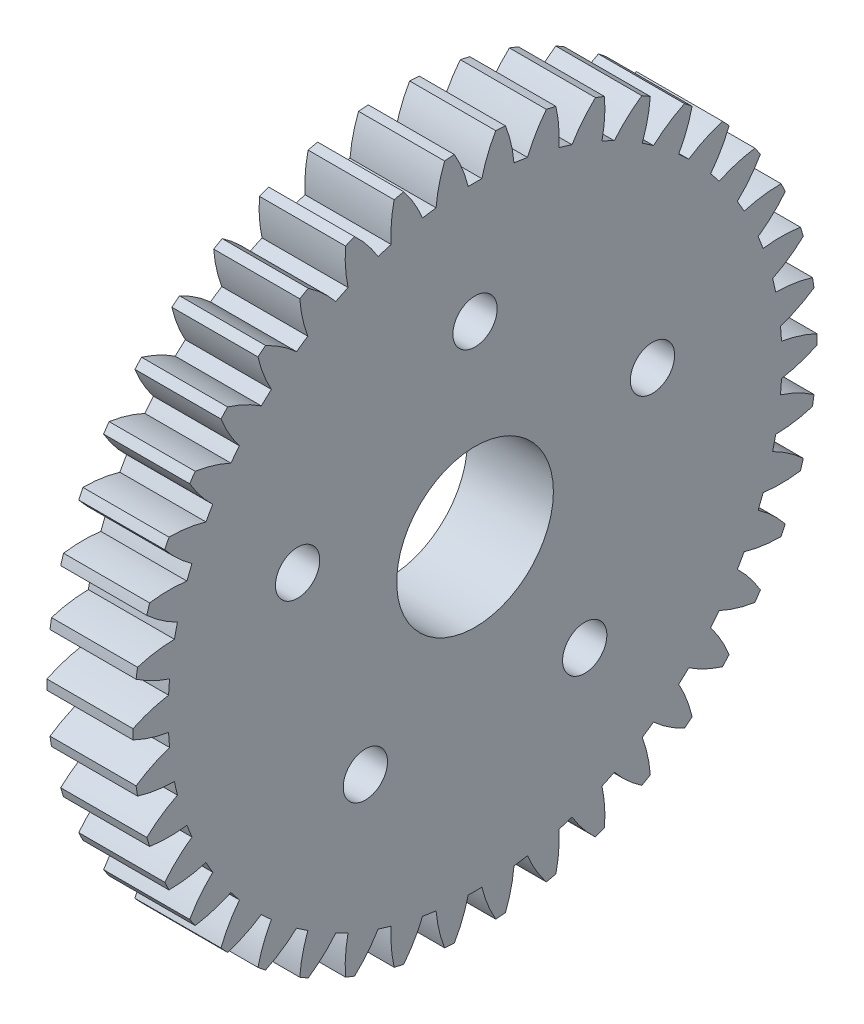
from build123d import *

# Parameters (mm, degrees)
BASPROSKE_W        = 4.3942
BASPROSKE_H        = 17.4625
TOOTHCUT_DEPTH     = 26.083596356
TEETHCUTS_COUNT    = 42
TEETHCUTS_ANGLE    = 351.428571429
BORSKE_R           = 0.396875
BORE_DEPTH         = 50.8000508
SKETCH1_R          = 4
SKETCH1_R_2        = 1.1303
CUT_EXTRUDE1_DEPTH = 7.366


with BuildPart() as part:
    # BasProSke → Base-Revolve (revolve)
    with BuildSketch(Plane(origin=(0, 0, 0), x_dir=(1, 0, 0), z_dir=(0, 1, 0)), mode=Mode.PRIVATE) as base_revolve_sk:
        with Locations((2.1971, 8.73125)):
            Rectangle(BASPROSKE_W, BASPROSKE_H)
    revolve(base_revolve_sk.sketch.rotate(Axis((-10, 0, 0), (1, 0, 0)), 180), axis=Axis((-10, 0, 0), (1, 0, 0)))

    # TooCutSke → ToothCut (cut, through all)
    with BuildSketch(Plane(origin=(0, 0, 0), x_dir=(0, 0, -1), z_dir=(1, 0, 0))):
        with BuildLine():
            ThreePointArc((0.348764079, 15.661567205), (0, 15.66545), (-0.348764079, 15.661567205))
            ThreePointArc((-0.348764079, 15.661567205), (-0.644200617, 16.584632497), (-1.070338344, 17.455114501))
            ThreePointArc((-1.070338344, 17.455114501), (0, 17.4879), (1.070338344, 17.455114501))
            ThreePointArc((1.070338344, 17.455114501), (0.644200617, 16.584632497), (0.348764079, 15.661567205))
        make_face()
    toothcut = extrude(amount=TOOTHCUT_DEPTH, mode=Mode.SUBTRACT)

    # TeethCuts: ToothCut ×42 about axis
    teethcuts_axis = Axis((-10, 0, 0), (1, 0, 0))
    for i in range(1, TEETHCUTS_COUNT):
        add(toothcut.rotate(teethcuts_axis, i * TEETHCUTS_ANGLE / (TEETHCUTS_COUNT - 1)), mode=Mode.SUBTRACT)

    # BorSke → Bore (cut, symmetric)
    with BuildSketch(Plane(origin=(0, 0, 0), x_dir=(0, 0, -1), z_dir=(1, 0, 0))):
        with Locations(Location((0, 0, 0), (0, 0, 180))):
            Circle(BORSKE_R)
    extrude(amount=BORE_DEPTH, both=True, mode=Mode.SUBTRACT)

    # Sketch1 → Cut-Extrude1 (cut)
    with BuildSketch(Plane(origin=(4.3942, 0, 0), x_dir=(0, 0, -1), z_dir=(1, 0, 0))):
        Circle(SKETCH1_R)
        with Locations((0, 9.525)):
            Circle(SKETCH1_R_2)
        with Locations((9.058813318, 2.943386871)):
            Circle(SKETCH1_R_2)
        with Locations((5.598654528, -7.705886871)):
            Circle(SKETCH1_R_2)
        with Locations((-5.598654528, -7.705886871)):
            Circle(SKETCH1_R_2)
        with Locations((-9.058813318, 2.943386871)):
            Circle(SKETCH1_R_2)
    extrude(amount=-CUT_EXTRUDE1_DEPTH, mode=Mode.SUBTRACT)


solid = part.part
